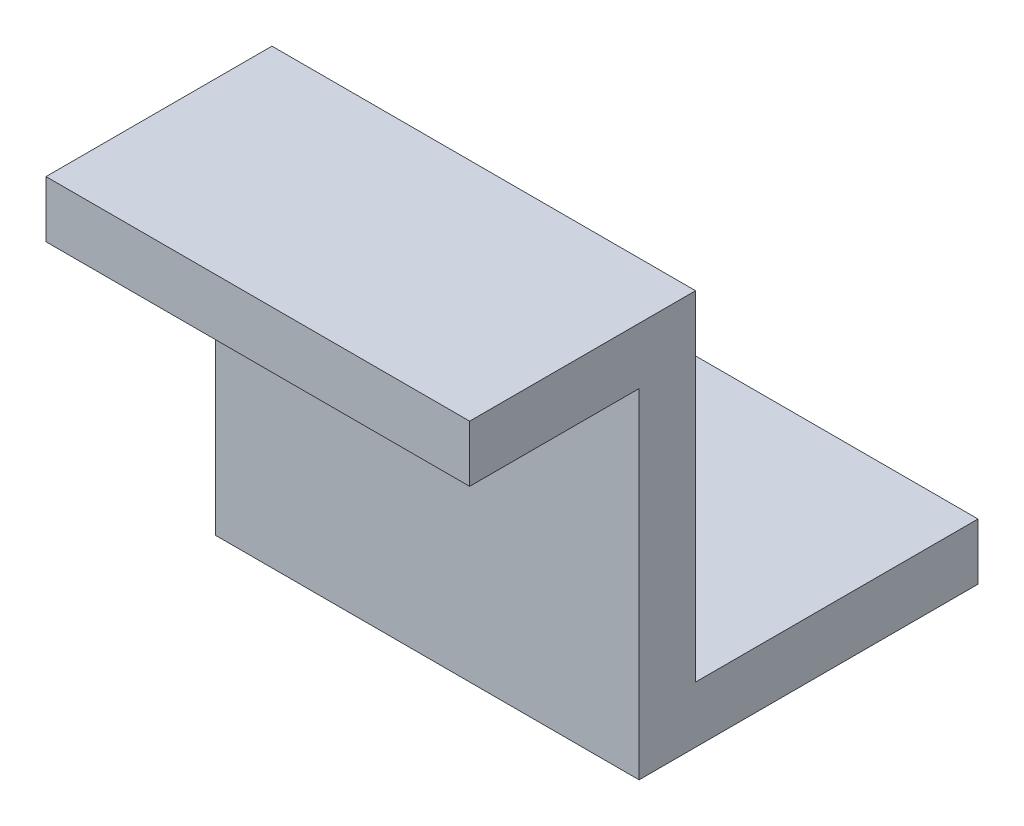
from build123d import *

# Parameters (mm, degrees)
BOSS_EXTRUDE1_DEPTH = 15
CUT_EXTRUDE1_REACH  = 4
SKETCH3_R           = 1.5


with BuildPart() as part:
    # Sketch1 → Boss-Extrude1 (new body)
    with BuildSketch(Plane(origin=(0, 0, 0), x_dir=(0, 0, -1), z_dir=(1, 0, 0))):
        Polygon((0, 0), (8, 0), (8, -12), (18, -12), (18, -14), (6, -14), (6, -2), (0, -2), align=None)
    extrude(amount=-BOSS_EXTRUDE1_DEPTH)

    # Sketch3 → Cut-Extrude1 (cut, up to next)
    with BuildSketch(Plane(origin=(0, -12, 0), x_dir=(1, 0, 0), z_dir=(0, 1, 0)), mode=Mode.PRIVATE) as cut_extrude1_sk1:
        with Locations((-7.5, 13)):
            Circle(SKETCH3_R)
    cut_extrude1_tool1 = extrude(cut_extrude1_sk1.sketch, amount=-CUT_EXTRUDE1_REACH, mode=Mode.PRIVATE) & part.part
    add(cut_extrude1_tool1.solids().sort_by_distance((-7.5, -12, -13))[0], mode=Mode.SUBTRACT)


solid = part.part
